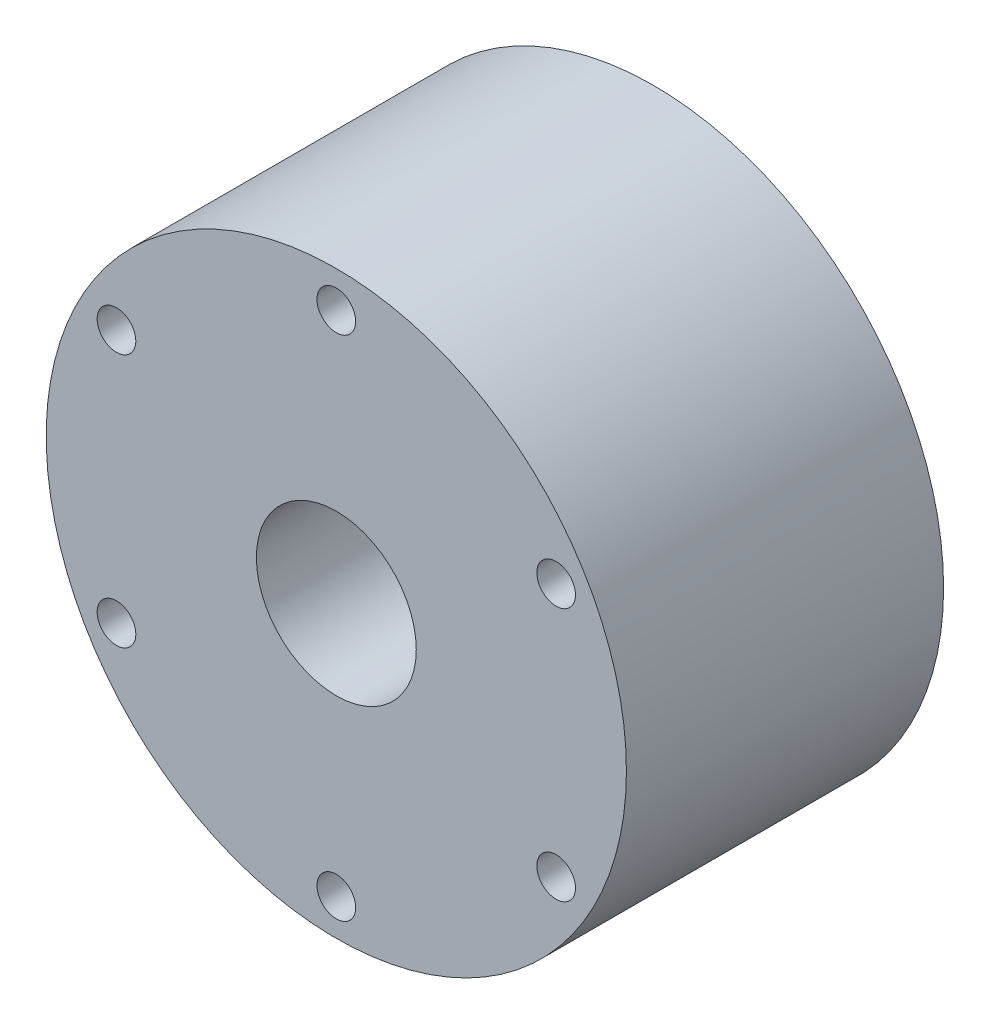
from build123d import *

# Parameters (mm, degrees)
SKETCH1_R           = 38.1
SKETCH1_R_2         = 10.5
BOSS_EXTRUDE1_DEPTH = 20.828
SKETCH6_R           = 17.75000006
CUT_EXTRUDE2_DEPTH  = 1.510000028
SKETCH8_R           = 2.54
CUT_EXTRUDE3_DEPTH  = 42.656
SKETCH9_R           = 14.09889992
CUT_EXTRUDE4_DEPTH  = 0.4


with BuildPart() as part:
    # Sketch1 → Boss-Extrude1 (new body, symmetric)
    with BuildSketch(Plane.XY):
        Circle(SKETCH1_R)
        Circle(SKETCH1_R_2, mode=Mode.SUBTRACT)
    extrude(amount=BOSS_EXTRUDE1_DEPTH, both=True)

    # Sketch6 → Cut-Extrude2 (cut)
    with BuildSketch(Plane(origin=(0, 0, -20.828), x_dir=(-1, 0, 0), z_dir=(0, 0, -1))):
        Circle(SKETCH6_R)
    extrude(amount=-CUT_EXTRUDE2_DEPTH, mode=Mode.SUBTRACT)

    # Sketch8 → Cut-Extrude3 (cut, through all)
    with BuildSketch(Plane.XY.offset(20.828)):
        with Locations((0, 33.3375)):
            Circle(SKETCH8_R)
        with Locations((28.871121899, 16.66875)):
            Circle(SKETCH8_R)
        with Locations((28.871121899, -16.66875)):
            Circle(SKETCH8_R)
        with Locations((0, -33.3375)):
            Circle(SKETCH8_R)
        with Locations((-28.871121899, -16.66875)):
            Circle(SKETCH8_R)
        with Locations((-28.871121899, 16.66875)):
            Circle(SKETCH8_R)
    extrude(amount=-CUT_EXTRUDE3_DEPTH, mode=Mode.SUBTRACT)

    # Sketch9 → Cut-Extrude4 (cut)
    with BuildSketch(Plane(origin=(0, 0, -19.317999972), x_dir=(-1, 0, 0), z_dir=(0, 0, -1))):
        Circle(SKETCH9_R)
    extrude(amount=-CUT_EXTRUDE4_DEPTH, mode=Mode.SUBTRACT)


solid = part.part
